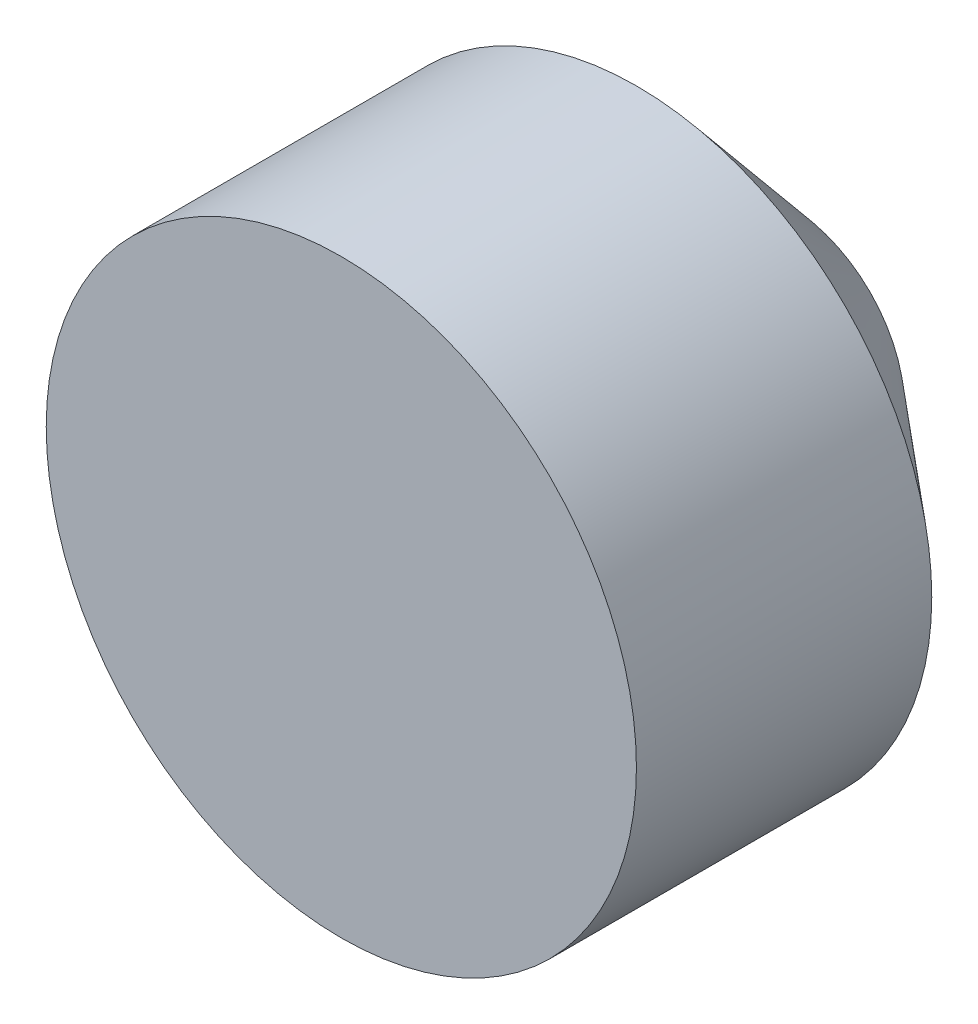
from build123d import *


with BuildPart() as part:
    # Sketch5 → Revolve1 (revolve)
    with BuildSketch(Plane(origin=(0, 0, 0), x_dir=(0, 0, -1), z_dir=(1, 0, 0))):
        Polygon((0, 0), (0, 500), (500.38, 500), (754.38, 200), (754.38, 0), align=None)
    revolve(axis=Axis((0, 0, -754.38), (0, 0, 1)))


solid = part.part
